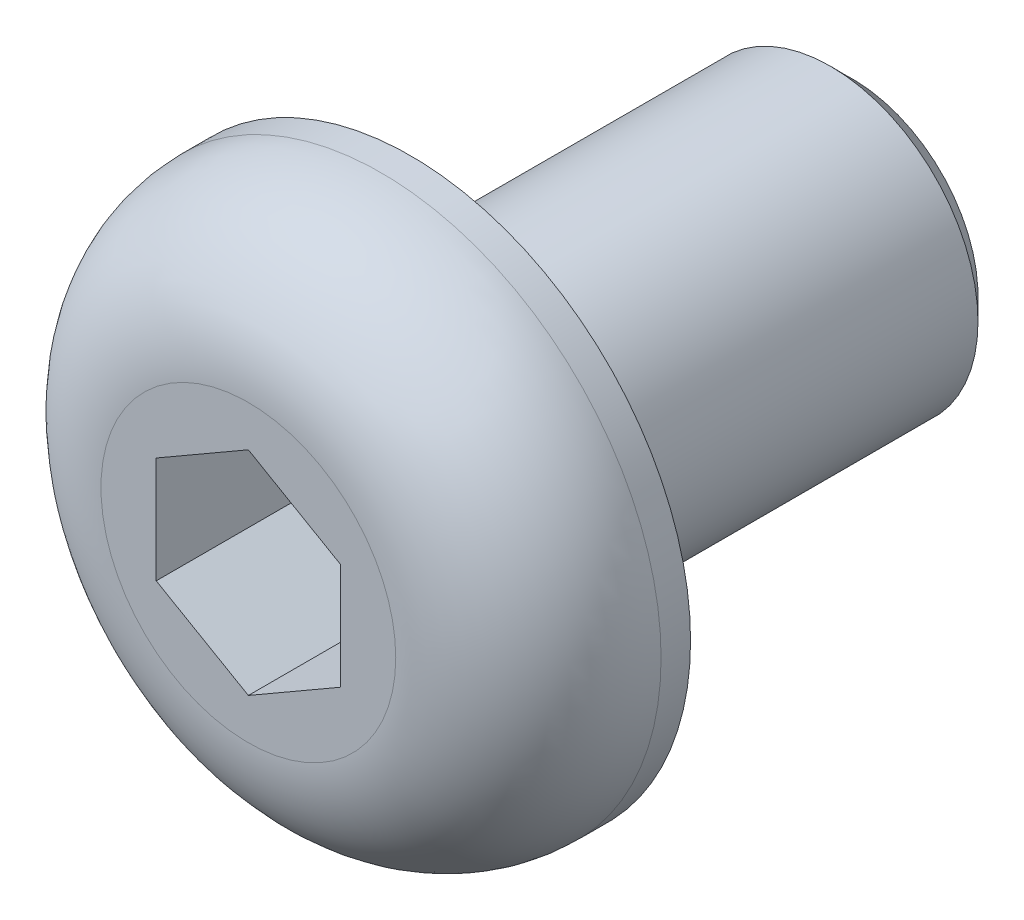
from build123d import *

# Parameters (mm, degrees)
SKETCH1_R           = 3.8
BOSS_EXTRUDE1_DEPTH = 2.2
SKETCH2_R           = 2
BOSS_EXTRUDE2_DEPTH = 6
CHAMFER1_SIZE       = 0.3
CUT_EXTRUDE1_DEPTH  = 2
FILLET1_R           = 1.8


with BuildPart() as part:
    # Sketch1 → Boss-Extrude1 (new body)
    with BuildSketch(Plane.XY):
        Circle(SKETCH1_R)
    extrude(amount=BOSS_EXTRUDE1_DEPTH)

    # Sketch2 → Boss-Extrude2 (add)
    with BuildSketch(Plane(origin=(0, 0, 0), x_dir=(-1, 0, 0), z_dir=(0, 0, -1))):
        Circle(SKETCH2_R)
    extrude(amount=BOSS_EXTRUDE2_DEPTH)

    # Chamfer1
    chamfer1_edges = [part.edges().sort_by_distance(p)[0] for p in [
        (2, 0, -6),
    ]]
    chamfer(chamfer1_edges, length=CHAMFER1_SIZE)

    # Sketch3 → Cut-Extrude1 (cut)
    with BuildSketch(Plane.XY.offset(2.2)):
        Polygon((0, 1.443375673), (-1.25, 0.721687836), (-1.25, -0.721687836), (0, -1.443375673), (1.25, -0.721687836), (1.25, 0.721687836), align=None)
    extrude(amount=-CUT_EXTRUDE1_DEPTH, mode=Mode.SUBTRACT)

    # Fillet1
    fillet1_edges = [part.edges().sort_by_distance(p)[0] for p in [
        (-3.8, 0, 2.2),
    ]]
    fillet(fillet1_edges, radius=FILLET1_R)


solid = part.part
